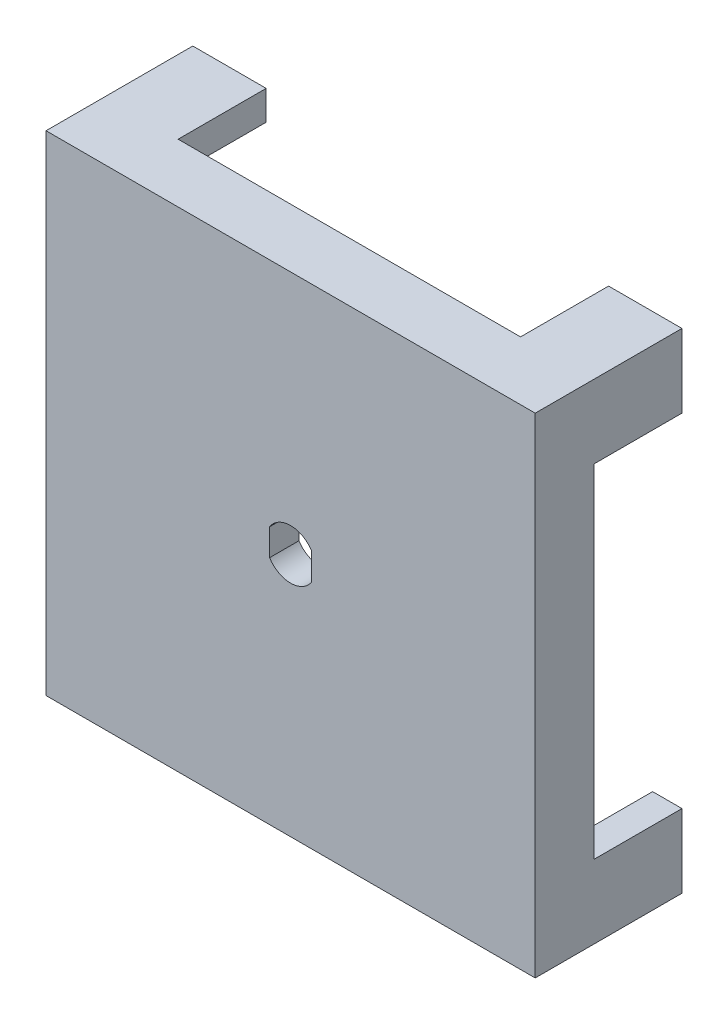
from build123d import *

# Parameters (mm, degrees)
SKETCH1_W               = 50
SKETCH1_H               = 50
BOSS_EXTRUDE1_DEPTH     = 15
SHELL1_T                = -3
CUT_EXTRUDE1_DEPTH      = 1
CUT_EXTRUDE1_DEPTH_BACK = 16
CUT_EXTRUDE2_DEPTH      = 9


with BuildPart() as part:
    # Sketch1 → Boss-Extrude1 (new body)
    with BuildSketch(Plane.XY):
        Rectangle(SKETCH1_W, SKETCH1_H)
    extrude(amount=BOSS_EXTRUDE1_DEPTH)

    # Shell1
    shell1_openings = [part.faces().sort_by_distance(p)[0] for p in [
        (0, 0, 0),
    ]]
    offset(amount=SHELL1_T, openings=shell1_openings, kind=Kind.INTERSECTION)

    # Sketch2 → Cut-Extrude1 (cut, two sides)
    with BuildSketch(Plane(origin=(0, 0, 0), x_dir=(-1, 0, 0), z_dir=(0, 0, -1))) as cut_extrude1_sk:
        with BuildLine():
            Line((-2.15, 1.37113092), (-2.15, -1.37113092))
            ThreePointArc((-2.15, -1.37113092), (0, -2.55), (2.15, -1.37113092))
            Line((2.15, -1.37113092), (2.15, 1.37113092))
            ThreePointArc((2.15, 1.37113092), (0, 2.55), (-2.15, 1.37113092))
        make_face()
    extrude(amount=CUT_EXTRUDE1_DEPTH, mode=Mode.SUBTRACT)
    extrude(cut_extrude1_sk.sketch, amount=-CUT_EXTRUDE1_DEPTH_BACK, mode=Mode.SUBTRACT)

    # Sketch4 → Cut-Extrude2 (cut)
    with BuildSketch(Plane(origin=(0, 0, 0), x_dir=(-1, 0, 0), z_dir=(0, 0, -1))):
        Polygon((-17.5, 17.5), (-17.5, 27.948399717), (17.5, 27.948399717), (17.5, 17.5), (26.941451912, 17.5), (26.941451912, -17.5), (17.5, -17.5), (17.5, -27.948399717), (-17.5, -27.948399717), (-17.5, -17.5), (-26.941451912, -17.5), (-26.941451912, 17.5), align=None)
    extrude(amount=-CUT_EXTRUDE2_DEPTH, mode=Mode.SUBTRACT)


solid = part.part
